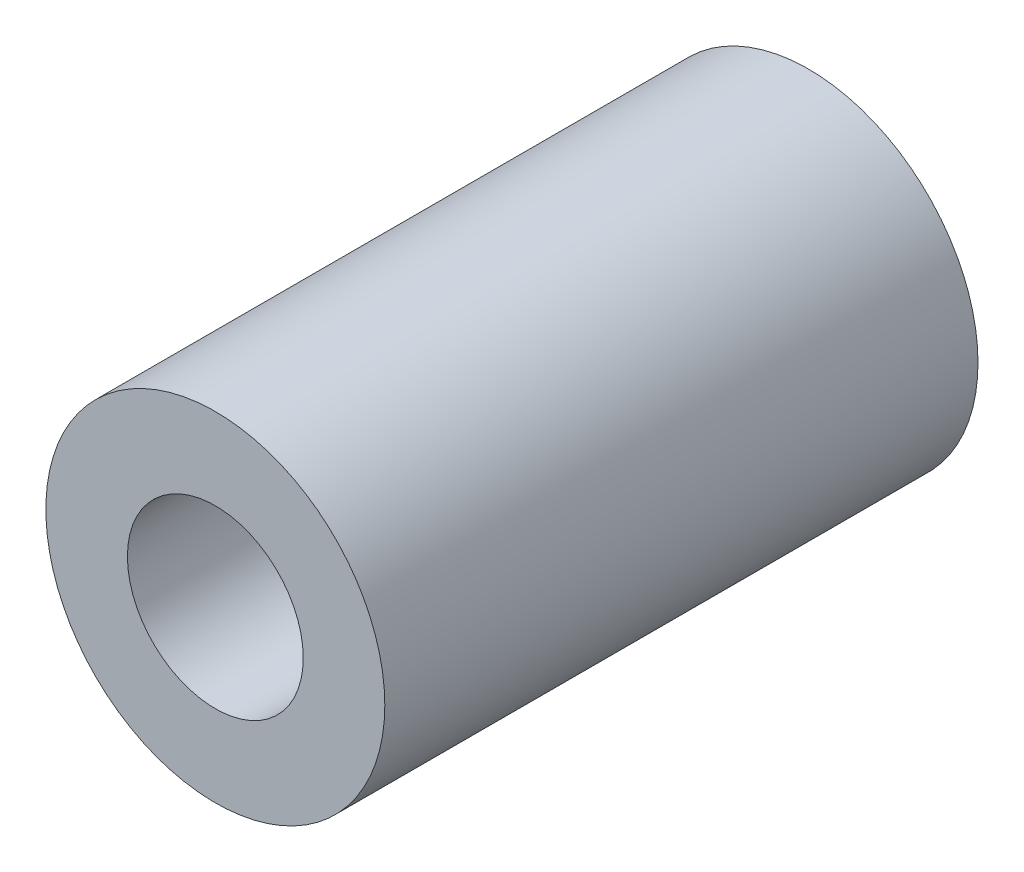
from build123d import *

# Parameters (mm, degrees)
SKETCH1_R           = 8
SKETCH1_R_2         = 4.15
BOSS_EXTRUDE1_DEPTH = 28


with BuildPart() as part:
    # Sketch1 → Boss-Extrude1 (new body)
    with BuildSketch(Plane.XY):
        Circle(SKETCH1_R)
        Circle(SKETCH1_R_2, mode=Mode.SUBTRACT)
    extrude(amount=BOSS_EXTRUDE1_DEPTH)


solid = part.part
